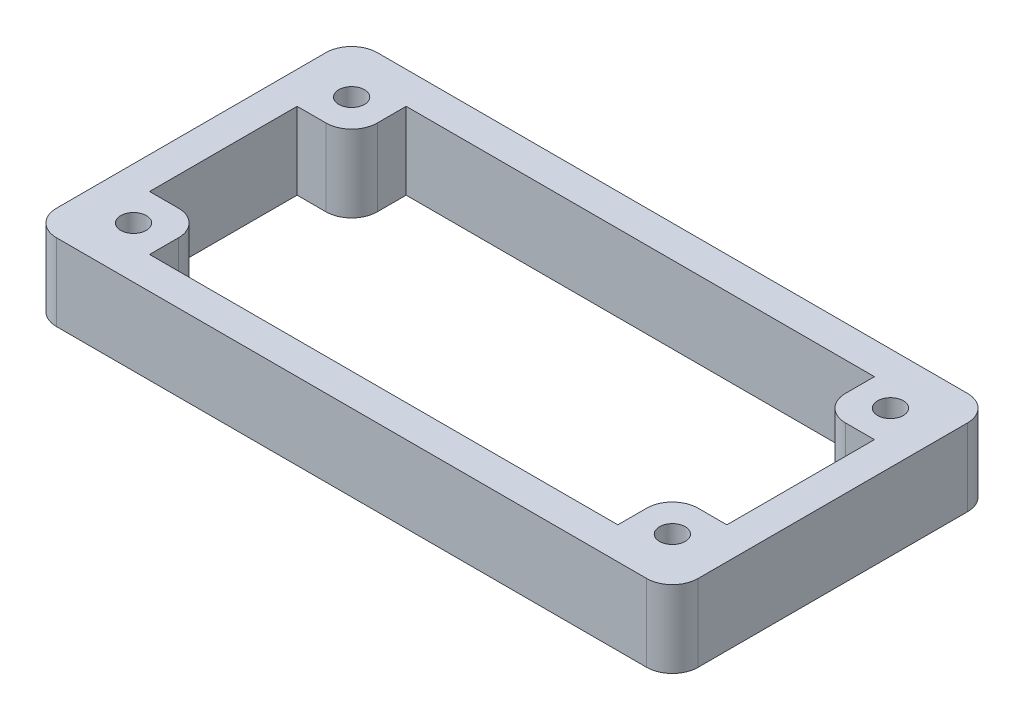
from build123d import *

# Parameters (mm, degrees)
SKETCH1_W           = 50
SKETCH1_H           = 25
BOSS_EXTRUDE1_DEPTH = 6
SKETCH2_R           = 1
SKETCH2_R_2         = 0.999812185
CUT_EXTRUDE1_DEPTH  = 6
CUT_EXTRUDE2_DEPTH  = 6
FILLET1_R           = 2


with BuildPart() as part:
    # Sketch1 → Boss-Extrude1 (new body)
    with BuildSketch(Plane(origin=(0, 0, 0), x_dir=(1, 0, 0), z_dir=(0, 1, 0))):
        Rectangle(SKETCH1_W, SKETCH1_H)
    extrude(amount=BOSS_EXTRUDE1_DEPTH)

    # Sketch2 → Cut-Extrude1 (cut)
    with BuildSketch(Plane(origin=(0, 0, 0), x_dir=(1, 0, 0), z_dir=(0, 1, 0))):
        with Locations((-21, 8.5)):
            Circle(SKETCH2_R)
        with Locations((21, 8.5)):
            Circle(SKETCH2_R_2)
        with Locations((-21, -8.5)):
            Circle(SKETCH2_R)
        with Locations((21, -8.5)):
            Circle(SKETCH2_R)
    extrude(amount=CUT_EXTRUDE1_DEPTH, mode=Mode.SUBTRACT)

    # Sketch3 → Cut-Extrude2 (cut)
    with BuildSketch(Plane(origin=(0, 0, 0), x_dir=(1, 0, 0), z_dir=(0, 1, 0))):
        Polygon((-22.5, 5.75), (-22.5, -5.75), (-18.25, -5.75), (-18.25, -10), (18.25, -10), (18.25, -5.75), (22.5, -5.75), (22.5, 5.75), (18.25, 5.75), (18.25, 10), (-18.25, 10), (-18.25, 5.75), align=None)
    extrude(amount=CUT_EXTRUDE2_DEPTH, mode=Mode.SUBTRACT)

    # Fillet1
    fillet1_edges = [part.edges().sort_by_distance(p)[0] for p in [
        (-18.25, 3, -5.75),
        (-18.25, 3, 5.75),
        (18.25, 3, 5.75),
        (18.25, 3, -5.75),
        (25, 3, 12.5),
        (-25, 3, 12.5),
        (-25, 3, -12.5),
        (25, 3, -12.5),
    ]]
    fillet(fillet1_edges, radius=FILLET1_R)


solid = part.part
